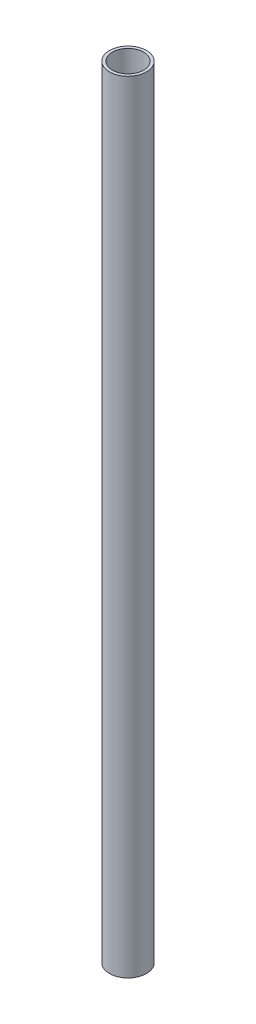
from build123d import *

# Parameters (mm, degrees)
SKETCH1_R           = 4.75
SKETCH1_R_2         = 4
BOSS_EXTRUDE1_DEPTH = 200


with BuildPart() as part:
    # Sketch1 → Boss-Extrude1 (new body)
    with BuildSketch(Plane(origin=(0, 0, 0), x_dir=(1, 0, 0), z_dir=(0, 1, 0))):
        Circle(SKETCH1_R)
        Circle(SKETCH1_R_2, mode=Mode.SUBTRACT)
    extrude(amount=BOSS_EXTRUDE1_DEPTH)


solid = part.part
